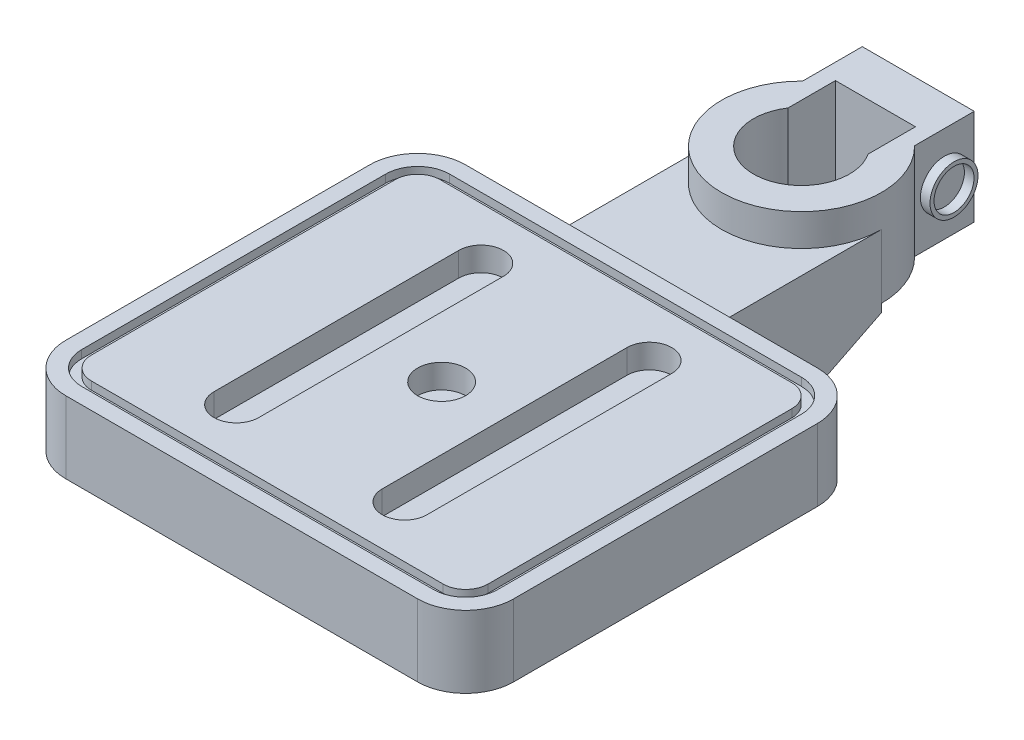
from build123d import *
from build123d.topology import SkipClean

# Parameters (mm, degrees)
BOSS_EXTRUDE1_DEPTH      = 40
CUT_EXTRUDE1_DEPTH       = 66
BOSS_EXTRUDE2_START      = -55
BOSS_EXTRUDE2_DEPTH      = 95
CUT_EXTRUDE2_DEPTH       = 256
BOSS_EXTRUDE3_DEPTH      = 5
BOSS_EXTRUDE3_DEPTH_BACK = 40
BOSS_EXTRUDE4_DEPTH      = 20
CUT_EXTRUDE3_DEPTH       = 5
BOSS_EXTRUDE5_DEPTH      = 5
SKETCH9_R                = 15
CUT_EXTRUDE5_DEPTH       = 15
SKETCH10_W               = 100
SKETCH10_H               = 55
BOSS_EXTRUDE6_DEPTH      = 140
CUT_EXTRUDE6_DEPTH       = 55
SKETCH12_R               = 15
BOSS_EXTRUDE7_DEPTH      = 6
SKETCH13_R               = 12.5
CUT_EXTRUDE7_DEPTH       = 6


with BuildPart() as part:
    # Sketch1 → Boss-Extrude1 (new body)
    with BuildSketch(Plane(origin=(0, 0, 0), x_dir=(1, 0, 0), z_dir=(0, 1, 0))):
        with BuildLine():
            Line((-35, 73), (35, 73))
            Line((35, 73), (35, 35.707142143))
            ThreePointArc((35, 35.707142143), (0, -50), (-35, 35.707142143))
            Line((-35, 35.707142143), (-35, 73))
        make_face()
    extrude(amount=BOSS_EXTRUDE1_DEPTH)

    # Sketch2 → Cut-Extrude1 (cut)
    with BuildSketch(Plane(origin=(0, 40, 0), x_dir=(1, 0, 0), z_dir=(0, 1, 0))):
        with BuildLine():
            Line((-25.015, 16.587646005), (-25.015, 46.245))
            Line((-25.015, 46.245), (25.015, 46.245))
            Line((25.015, 46.245), (25.015, 16.587646005))
            ThreePointArc((25.015, 16.587646005), (0, -30.015), (-25.015, 16.587646005))
        make_face()
    extrude(amount=-CUT_EXTRUDE1_DEPTH, mode=Mode.SUBTRACT)

    # Sketch3 → Boss-Extrude2 (add)
    with SkipClean():  # the faces are left unmerged after this step: merging them gives an invalid solid
        with BuildSketch(Plane(origin=(0, 0, 0), x_dir=(1, 0, 0), z_dir=(0, 1, 0)).offset(BOSS_EXTRUDE2_START)):
            with BuildLine():
                Line((30.015, 0), (50, 0))
                Line((50, 0), (50, -100))
                Line((50, -100), (-50, -100))
                Line((-50, -100), (-50, 0))
                Line((-50, 0), (-30.015, 0))
                ThreePointArc((-30.015, 0), (0, -30.015), (30.015, 0))
            make_face()
        extrude(amount=BOSS_EXTRUDE2_DEPTH)

    # Sketch4 → Cut-Extrude2 (cut)
    with SkipClean():  # the faces are left unmerged after this step: merging them gives an invalid solid
        with BuildSketch(Plane(origin=(50, 0, 0), x_dir=(0, 0, -1), z_dir=(1, 0, 0))):
            Polygon((-100, -55), (0, -5.02758566), (0, -55), align=None)
        extrude(amount=-CUT_EXTRUDE2_DEPTH, mode=Mode.SUBTRACT)

    # Sketch5 → Boss-Extrude3 (add, two sides: drawn at the far end of the back side and taken through both)
    with SkipClean():  # the faces are left unmerged after this step: merging them gives an invalid solid
        with BuildSketch(Plane(origin=(0, 40, 0), x_dir=(1, 0, 0), z_dir=(0, 1, 0)).offset(-BOSS_EXTRUDE3_DEPTH_BACK)):
            with BuildLine():
                Line((-110, -350), (110, -350))
                ThreePointArc((110, -350), (131.213203436, -341.213203436), (140, -320))
                Line((140, -320), (140, -130))
                ThreePointArc((140, -130), (131.213203436, -108.786796564), (110, -100))
                Line((110, -100), (-110, -100))
                ThreePointArc((-110, -100), (-131.213203436, -108.786796564), (-140, -130))
                Line((-140, -130), (-140, -320))
                ThreePointArc((-140, -320), (-131.213203436, -341.213203436), (-110, -350))
            make_face()
        extrude(amount=BOSS_EXTRUDE3_DEPTH + BOSS_EXTRUDE3_DEPTH_BACK)

    # Sketch6 → Boss-Extrude4 (add)
    with SkipClean():  # the faces are left unmerged after this step: merging them gives an invalid solid
        with BuildSketch(Plane(origin=(0, 40, 0), x_dir=(1, 0, 0), z_dir=(0, 1, 0))):
            with BuildLine():
                Line((-35, 35.707142143), (-35, 73))
                Line((-35, 73), (35, 73))
                Line((35, 73), (35, 35.707142143))
                ThreePointArc((35, 35.707142143), (0, -50), (-35, 35.707142143))
            make_face()
            with BuildLine():
                Line((-25.015, 16.587646005), (-25.015, 46.245))
                Line((-25.015, 46.245), (25.015, 46.245))
                Line((25.015, 46.245), (25.015, 16.587646005))
                ThreePointArc((25.015, 16.587646005), (0, -30.015), (-25.015, 16.587646005))
            make_face(mode=Mode.SUBTRACT)
        extrude(amount=BOSS_EXTRUDE4_DEPTH)

    # Sketch7 → Cut-Extrude3 (cut)
    with SkipClean():  # the faces are left unmerged after this step: merging them gives an invalid solid
        with BuildSketch(Plane(origin=(0, 45, 0), x_dir=(1, 0, 0), z_dir=(0, 1, 0))):
            with BuildLine():
                Line((130, -320), (130, -130))
                ThreePointArc((130, -130), (124.142135624, -115.857864376), (110, -110))
                Line((110, -110), (-110, -110))
                ThreePointArc((-110, -110), (-124.142135624, -115.857864376), (-130, -130))
                Line((-130, -130), (-130, -320))
                ThreePointArc((-130, -320), (-124.142135624, -334.142135624), (-110, -340))
                Line((-110, -340), (110, -340))
                ThreePointArc((110, -340), (124.142135624, -334.142135624), (130, -320))
            make_face()
        extrude(amount=-CUT_EXTRUDE3_DEPTH, mode=Mode.SUBTRACT)

    # Sketch8 → Boss-Extrude5 (add)
    with SkipClean():  # the faces are left unmerged after this step: merging them gives an invalid solid
        with BuildSketch(Plane(origin=(0, 40, 0), x_dir=(1, 0, 0), z_dir=(0, 1, 0))):
            with BuildLine():
                Line((124, -320), (124, -130))
                ThreePointArc((124, -130), (119.899494937, -120.100505063), (110, -116))
                Line((110, -116), (-110, -116))
                ThreePointArc((-110, -116), (-119.899494937, -120.100505063), (-124, -130))
                Line((-124, -130), (-124, -320))
                ThreePointArc((-124, -320), (-119.899494937, -329.899494937), (-110, -334))
                Line((-110, -334), (110, -334))
                ThreePointArc((110, -334), (119.899494937, -329.899494937), (124, -320))
            make_face()
        extrude(amount=BOSS_EXTRUDE5_DEPTH)

    # Sketch9 → Cut-Extrude5 (cut)
    with SkipClean():  # the faces are left unmerged after this step: merging them gives an invalid solid
        with BuildSketch(Plane(origin=(0, 45, 0), x_dir=(1, 0, 0), z_dir=(0, 1, 0))):
            with Locations(Location((0, -225, 0), (0, 0, 270))):
                Circle(SKETCH9_R)
            with BuildLine():
                Line((-65.823520443, -301.518564523), (-65.823520443, -148.481435477))
                ThreePointArc((-65.823520443, -148.481435477), (-51.823520443, -134.481435477), (-37.823520443, -148.481435477))
                Line((-37.823520443, -148.481435477), (-37.823520443, -301.518564523))
                ThreePointArc((-37.823520443, -301.518564523), (-51.823520443, -315.518564523), (-65.823520443, -301.518564523))
            make_face()
            with BuildLine():
                Line((39.386204855, -301.518564523), (39.386204855, -148.481435477))
                ThreePointArc((39.386204855, -148.481435477), (53.386204855, -134.481435477), (67.386204855, -148.481435477))
                Line((67.386204855, -148.481435477), (67.386204855, -301.518564523))
                ThreePointArc((67.386204855, -301.518564523), (53.386204855, -315.518564523), (39.386204855, -301.518564523))
            make_face()
        extrude(amount=-CUT_EXTRUDE5_DEPTH, mode=Mode.SUBTRACT)

    # Sketch10 → Boss-Extrude6 (add)
    with SkipClean():  # the faces are left unmerged after this step: merging them gives an invalid solid
        with BuildSketch(Plane.XY.offset(100)):
            with Locations((0, -27.5)):
                Rectangle(SKETCH10_W, SKETCH10_H)
        extrude(amount=BOSS_EXTRUDE6_DEPTH)

    # Sketch11 → Cut-Extrude6 (cut)
    with SkipClean():  # the faces are left unmerged after this step: merging them gives an invalid solid
        with BuildSketch(Plane.XZ.offset(55)):
            with BuildLine():
                Line((50, 240), (0, 240))
                ThreePointArc((0, 240), (27.117470016, 234.534043883), (50, 218.989794856))
                Line((50, 218.989794856), (50, 240))
            make_face()
            with BuildLine():
                Line((0, 240), (-50, 240))
                Line((-50, 240), (-50, 218.989794856))
                ThreePointArc((-50, 218.989794856), (-27.117470016, 234.534043883), (0, 240))
            make_face()
        extrude(amount=-CUT_EXTRUDE6_DEPTH, mode=Mode.SUBTRACT)

    # Sketch12 → Boss-Extrude7 (add)
    with SkipClean():  # the faces are left unmerged after this step: merging them gives an invalid solid
        with BuildSketch(Plane(origin=(35, 0, 0), x_dir=(0, 0, -1), z_dir=(1, 0, 0))):
            with Locations(Location((54.353571071, 30, 0), (0, 0, 180))):
                Circle(SKETCH12_R)
        extrude(amount=BOSS_EXTRUDE7_DEPTH)

    # Sketch13 → Cut-Extrude7 (cut)
    with SkipClean():  # the faces are left unmerged after this step: merging them gives an invalid solid
        with BuildSketch(Plane(origin=(41, 0, 0), x_dir=(0, 0, -1), z_dir=(1, 0, 0))):
            with Locations((54.353571071, 30)):
                Circle(SKETCH13_R)
        extrude(amount=-CUT_EXTRUDE7_DEPTH, mode=Mode.SUBTRACT)


solid = part.part
